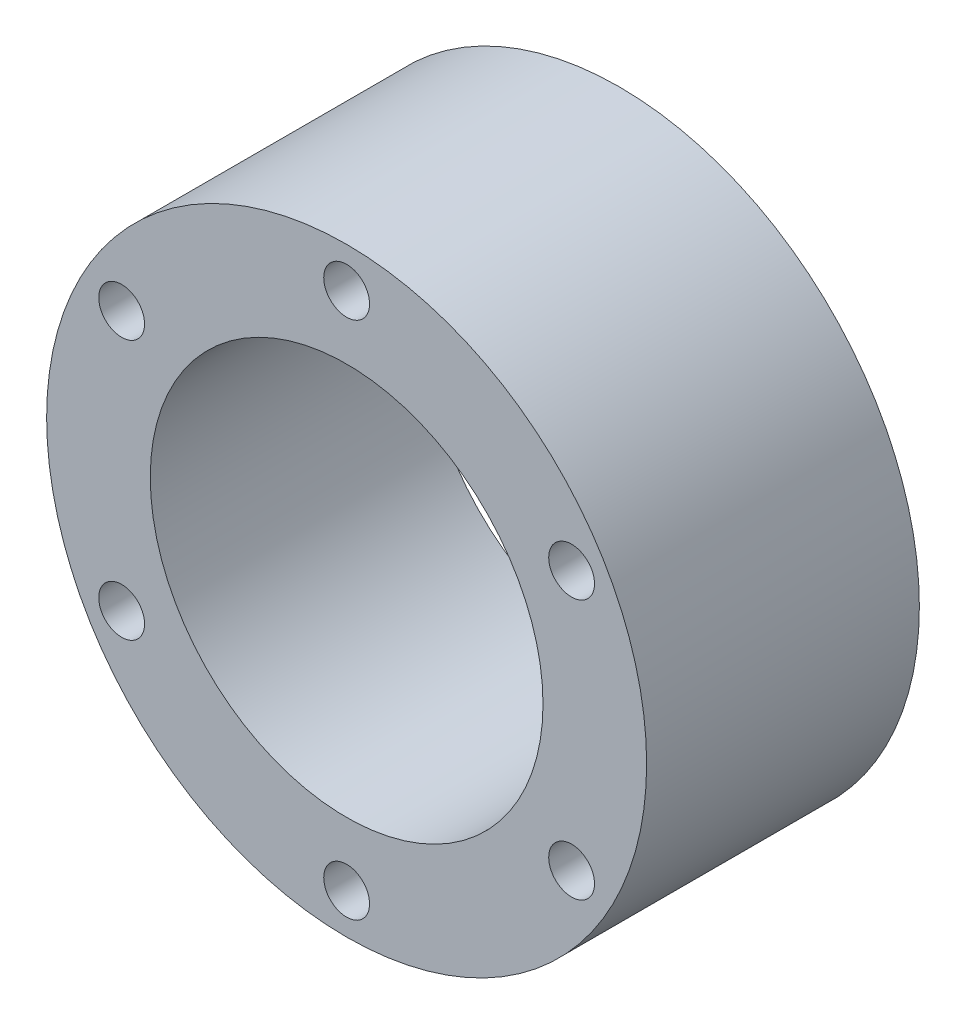
from build123d import *

# Parameters (mm, degrees)
SKETCH2_R                       = 27.5
SKETCH2_R_2                     = 18
BOSS_EXTRUDE1_DEPTH             = 12.5
TAP_DRILL_FOR_M5X0_8_TAP1_D     = 4.2
TAP_DRILL_FOR_M5X0_8_TAP1_DEPTH = 25.001
CIRPATTERN5_COUNT               = 6


with BuildPart() as part:
    # Sketch2 → Boss-Extrude1 (new body, symmetric)
    with BuildSketch(Plane.XY):
        Circle(SKETCH2_R)
        Circle(SKETCH2_R_2, mode=Mode.SUBTRACT)
    extrude(amount=BOSS_EXTRUDE1_DEPTH, both=True)

    # Tap Drill for M5x0.8 Tap1
    with Locations(Plane(origin=(0, 0, -12.5), x_dir=(-1, 0, 0), z_dir=(0, 0, -1))):
        with Locations((0, 23.8125)):
            tap_drill_for_m5x0_8_tap1 = Hole(TAP_DRILL_FOR_M5X0_8_TAP1_D / 2, depth=TAP_DRILL_FOR_M5X0_8_TAP1_DEPTH)

    # CirPattern5: Tap Drill for M5x0.8 Tap1 ×6 about axis
    cirpattern5_axis = Axis((0, 0, 0), (0, 0, 1))
    for i in range(1, CIRPATTERN5_COUNT):
        add(tap_drill_for_m5x0_8_tap1.rotate(cirpattern5_axis, i * 360 / CIRPATTERN5_COUNT), mode=Mode.SUBTRACT)


solid = part.part
